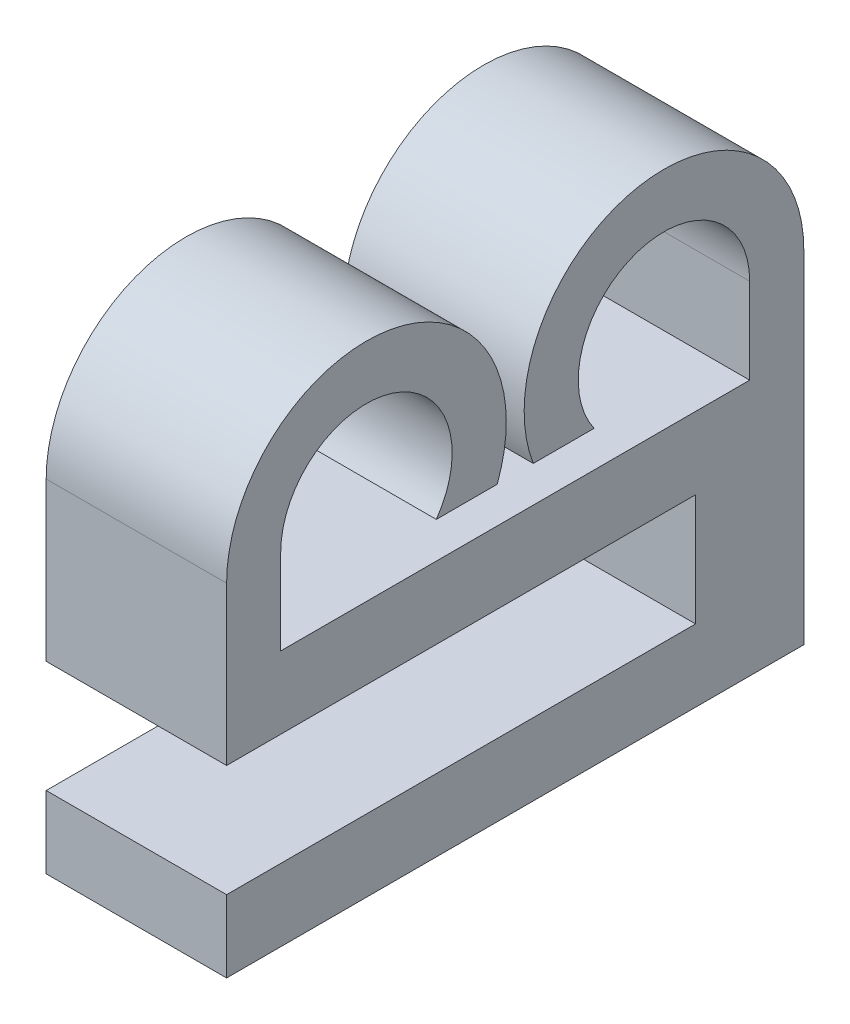
from build123d import *

# Parameters (mm, degrees)
BOSS_EXTRUDE1_DEPTH = 5
BOSS_EXTRUDE2_DEPTH = 5


with BuildPart() as part:
    # Sketch1 → Boss-Extrude1 (new body)
    with BuildSketch(Plane(origin=(0, 0, 0), x_dir=(0, 0, -1), z_dir=(1, 0, 0))):
        with BuildLine():
            Line((-7.997844187, 2.375), (-7.997844187, -2))
            Line((-7.997844187, -2), (7.997844187, -2))
            Line((7.997844187, -2), (7.997844187, 2.375))
            ThreePointArc((7.997844187, 2.375), (3.423879317, 6.186439769), (0.5, 1))
            Line((0.5, 1), (2.186352513, 1))
            ThreePointArc((2.186352513, 1), (3.401228889, 4.637718799), (6.497844187, 2.375))
            Line((6.497844187, 2.375), (6.497844187, 0))
            Line((6.497844187, 0), (-6.497844187, 0))
            Line((-6.497844187, 0), (-6.497844187, 2.375))
            ThreePointArc((-6.497844187, 2.375), (-3.401228889, 4.637718799), (-2.186352513, 1))
            Line((-2.186352513, 1), (-0.5, 1))
            ThreePointArc((-0.5, 1), (-3.423879317, 6.186439769), (-7.997844187, 2.375))
        make_face()
    extrude(amount=BOSS_EXTRUDE1_DEPTH)

    # Sketch2 → Boss-Extrude2 (add)
    with BuildSketch(Plane.ZY):
        Polygon((-7.997844187, -2), (-7.997844187, -7.1), (7.997844187, -7.1), (7.997844187, -5.1), (-4.997844187, -5.1), (-4.997844187, -2), align=None)
    extrude(amount=-BOSS_EXTRUDE2_DEPTH)


solid = part.part
